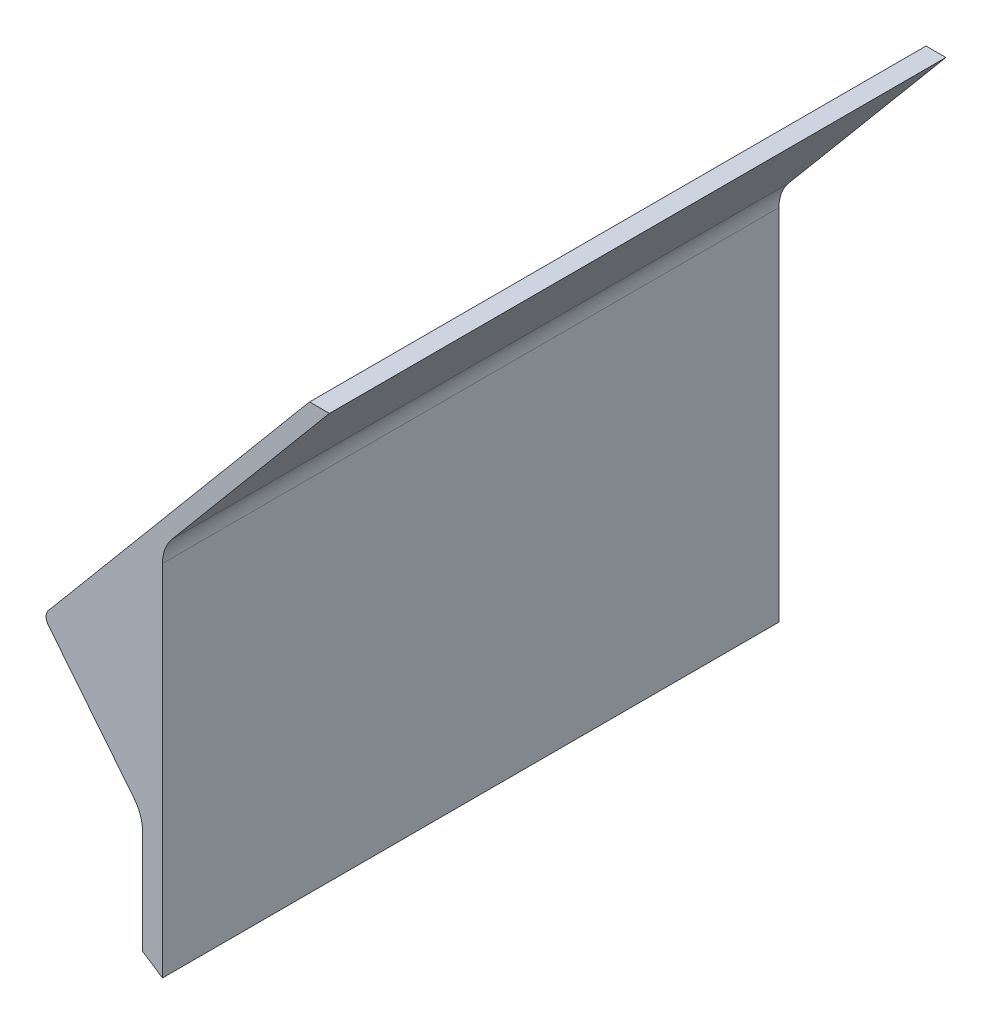
from build123d import *

# Parameters (mm, degrees)
FUNNEL_RIGHT_SIDE_DEPTH = 155
FILLET2_R               = 10
FILLET3_R               = 2.5


with BuildPart() as part:
    # Sketch1 → Funnel - Right Side (new body)
    with BuildSketch(Plane.XY):
        with BuildLine():
            Line((0, 0), (0, 93.9))
            Line((0, 93.9), (41.974030913, 143.922702136))
            Line((41.974030913, 143.922702136), (36.974030913, 143.922702136))
            Line((36.974030913, 143.922702136), (-30, 64.106160185))
            Line((-30, 64.106160185), (-5, 32.881170193))
            Line((-5, 32.881170193), (-5, 3.266851564))
            ThreePointArc((-5, 3.266851564), (-2.484755158, 1.656758403), (0, 0))
        make_face()
    extrude(amount=FUNNEL_RIGHT_SIDE_DEPTH)

    # Fillet2
    fillet2_edges = [part.edges().sort_by_distance(p)[0] for p in [
        (-5, 32.881170193, 77.5),
        (0, 93.9, 77.5),
    ]]
    fillet(fillet2_edges, radius=FILLET2_R)

    # Fillet3
    fillet3_edges = [part.edges().sort_by_distance(p)[0] for p in [
        (-30, 64.106160185, 77.5),
    ]]
    fillet(fillet3_edges, radius=FILLET3_R)


solid = part.part
